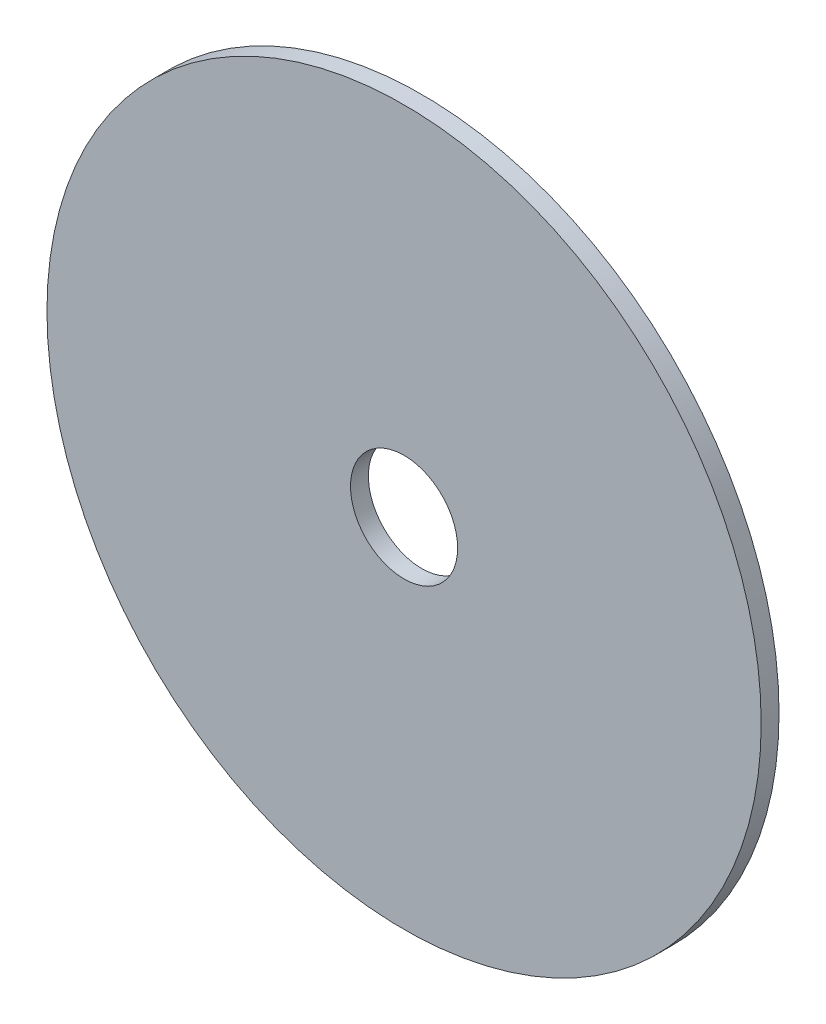
from build123d import *

# Parameters (mm, degrees)
SKETCH2_R           = 100
SKETCH2_R_2         = 15
BOSS_EXTRUDE1_DEPTH = 5


with BuildPart() as part:
    # Sketch2 → Boss-Extrude1 (new body)
    with BuildSketch(Plane.XY):
        Circle(SKETCH2_R)
        Circle(SKETCH2_R_2, mode=Mode.SUBTRACT)
    extrude(amount=BOSS_EXTRUDE1_DEPTH)


solid = part.part
